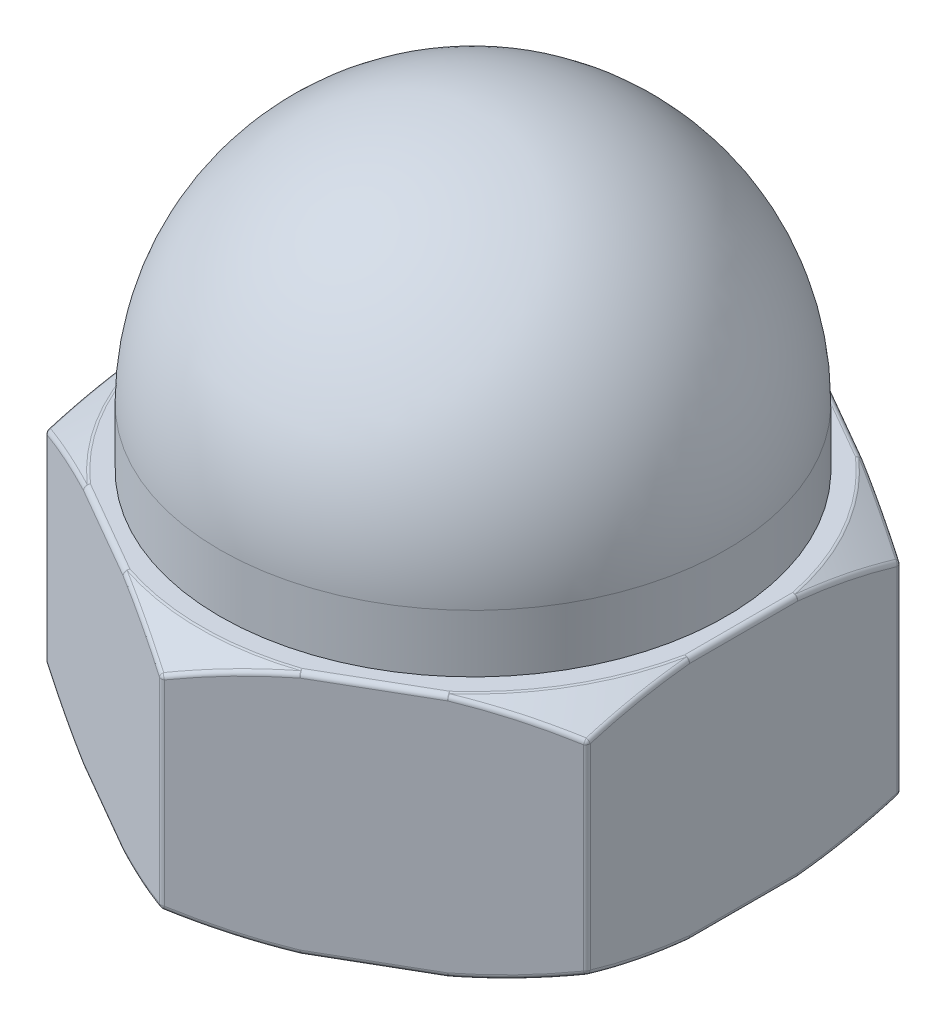
from build123d import *

# Parameters (mm, degrees)
SALIENTE_EXTRUIR1_DEPTH = 2.45
CROQUIS2_R              = 2.525
SALIENTE_EXTRUIR2_DEPTH = 3.1
REDONDEO1_R             = 2.525
REDONDEO2_R             = 0.05
CROQUIS4_R              = 1.15
CORTAR_EXTRUIR1_DEPTH   = 4.85
CHAFL_N1_SIZE           = 0.2


with BuildPart() as part:
    # Croquis1 → Saliente-Extruir1 (new body)
    with BuildSketch(Plane(origin=(0, 0, 0), x_dir=(1, 0, 0), z_dir=(0, 1, 0))):
        Polygon((-2.7, -1.558845727), (-2.7, 1.558845727), (0, 3.117691454), (2.7, 1.558845727), (2.7, -1.558845727), (0, -3.117691454), align=None)
    extrude(amount=SALIENTE_EXTRUIR1_DEPTH)

    # Croquis3 → Cortar-Revolución4 (revolve, cut)
    with BuildSketch(Plane(origin=(0, 0, 0), x_dir=(0.866025404, 0, -0.5), z_dir=(0.5, 0, 0.866025404))):
        with BuildLine():
            Line((3.117691454, 4.226402247), (3.117691454, 2.226402247))
            ThreePointArc((3.117691454, 2.226402247), (1.618886425, 2.87747408), (0, 3.1))
            Line((0, 3.1), (0, 4.226402247))
            Line((0, 4.226402247), (3.117691454, 4.226402247))
        make_face()
    cortar_revoluci_n4 = revolve(axis=Axis((0, 0, 0), (0, 1, 0)), mode=Mode.SUBTRACT)

    # Simetría1: Cortar-Revolución4 across plane
    add(cortar_revoluci_n4.mirror(Plane.ZX.offset(1.225)), mode=Mode.SUBTRACT)

    # Croquis2 → Saliente-Extruir2 (add)
    with BuildSketch(Plane(origin=(0, 2.45, 0), x_dir=(1, 0, 0), z_dir=(0, 1, 0))):
        Circle(CROQUIS2_R)
    extrude(amount=SALIENTE_EXTRUIR2_DEPTH)

    # Redondeo1
    redondeo1_edges = [part.edges().sort_by_distance(p)[0] for p in [
        (-2.525, 5.55, 0),
    ]]
    fillet(redondeo1_edges, radius=REDONDEO1_R)

    # Redondeo2
    redondeo2_edges = [part.edges().sort_by_distance(p)[0] for p in [
        (-2.7, 0, 0),
        (-2.7, 0.07386793, -0.934039818),
        (-2.7, 2.37613207, -0.934039818),
        (-2.7, 2.45, 0),
        (-2.7, 2.37613207, 0.934039818),
        (-2.7, 0.07386793, 0.934039818),
        (-1.35, 0, -2.33826859),
        (-0.54109779, 0.07386793, -2.805288499),
        (-0.54109779, 2.37613207, -2.805288499),
        (-1.35, 2.45, -2.33826859),
        (-2.15890221, 2.37613207, -1.871248681),
        (-2.7, 1.225, -1.558845727),
        (-2.15890221, 0.07386793, -1.871248681),
        (1.35, 0, -2.33826859),
        (2.15890221, 0.07386793, -1.871248681),
        (2.15890221, 2.37613207, -1.871248681),
        (1.35, 2.45, -2.33826859),
        (0.54109779, 2.37613207, -2.805288499),
        (0, 1.225, -3.117691454),
        (0.54109779, 0.07386793, -2.805288499),
        (2.7, 0, 0),
        (2.7, 0.07386793, 0.934039818),
        (2.7, 2.37613207, 0.934039818),
        (2.7, 2.45, 0),
        (2.7, 2.37613207, -0.934039818),
        (2.7, 1.225, -1.558845727),
        (2.7, 0.07386793, -0.934039818),
        (-1.35, 0, 2.33826859),
        (-2.15890221, 0.07386793, 1.871248681),
        (-2.7, 1.225, 1.558845727),
        (-2.15890221, 2.37613207, 1.871248681),
        (-1.35, 2.45, 2.33826859),
        (-0.54109779, 2.37613207, 2.805288499),
        (-0.54109779, 0.07386793, 2.805288499),
        (1.35, 0, 2.33826859),
        (0.54109779, 0.07386793, 2.805288499),
        (0, 1.225, 3.117691454),
        (0.54109779, 2.37613207, 2.805288499),
        (1.35, 2.45, 2.33826859),
        (2.15890221, 2.37613207, 1.871248681),
        (2.7, 1.225, 1.558845727),
        (2.15890221, 0.07386793, 1.871248681),
        (-2.352259552, 0, 1.358077686),
        (0, 0, 2.716155371),
        (2.352259552, 0, 1.358077686),
        (2.352259552, 0, -1.358077686),
        (0, 0, -2.716155371),
        (-2.352259552, 0, -1.358077686),
        (-2.352259552, 2.45, 1.358077686),
        (0, 2.45, 2.716155371),
        (2.352259552, 2.45, 1.358077686),
        (2.352259552, 2.45, -1.358077686),
        (0, 2.45, -2.716155371),
    ]]
    fillet(redondeo2_edges, radius=REDONDEO2_R)

    # Croquis4 → Cortar-Extruir1 (cut)
    with BuildSketch(Plane.XZ):
        Circle(CROQUIS4_R)
    extrude(amount=-CORTAR_EXTRUIR1_DEPTH, mode=Mode.SUBTRACT)

    # Chaflán1
    chafl_n1_edges = [part.edges().sort_by_distance(p)[0] for p in [
        (-1.15, 0, 0),
    ]]
    chamfer(chafl_n1_edges, length=CHAFL_N1_SIZE)


solid = part.part
